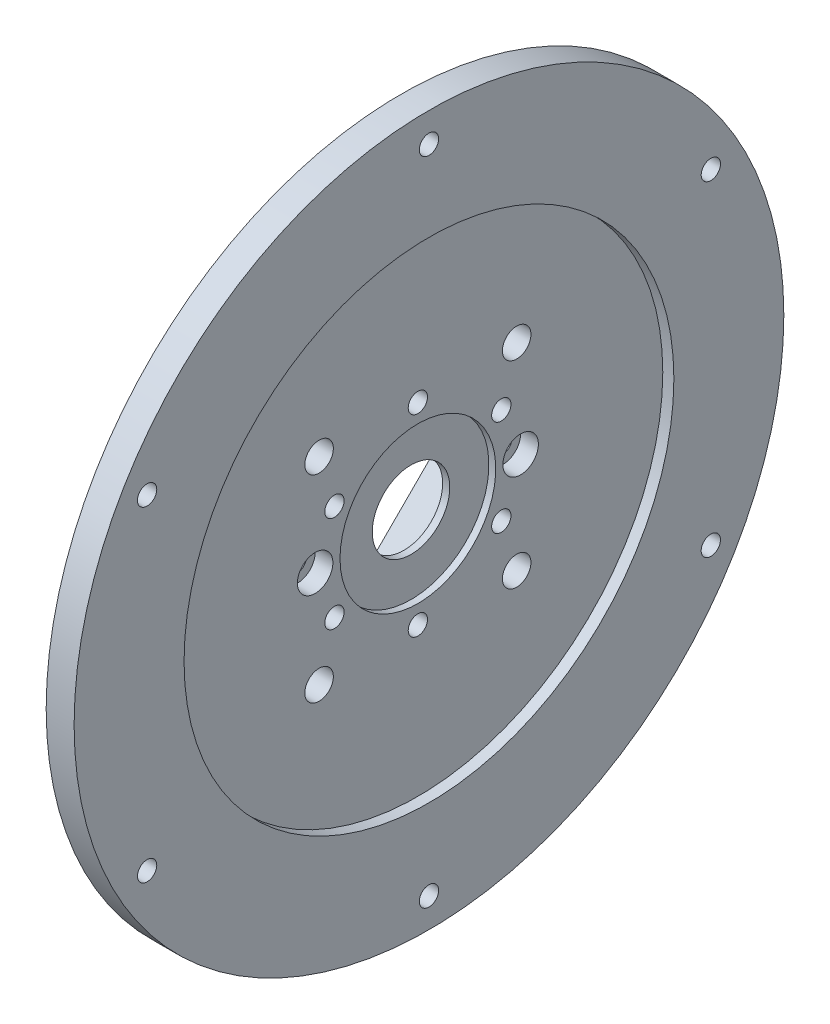
from build123d import *

# Parameters (mm, degrees)
SKETCH4_R               = 1.7272
CUT_EXTRUDE1_DEPTH      = 5.984800038
CUT_EXTRUDE1_DEPTH_BACK = 14.77519978
SKETCH5_R               = 1.5875
CUT_EXTRUDE2_DEPTH      = 17.775199622
SKETCH6_R               = 3.175
CUT_EXTRUDE3_DEPTH      = 3.175
BOSS_EXTRUDE1_REACH     = 20.76
FILLET1_R               = 3.175
SKETCH8_R               = 2.5527
CUT_EXTRUDE4_DEPTH      = 19.759999818


with BuildPart() as part:
    # Sketch2 → Revolve1 (revolve)
    with BuildSketch(Plane.XY):
        Polygon((-0.015199868, 29.999999944), (-1.815199824, 29.999999944), (-11.775199716, 29.999999944), (-13.77519978, 29.999999944), (-13.77519978, 25.4), (-2.000000064, 25.4), (-2.000000064, 11.499999987), (0.500000016, 11.499999987), (0.500000016, 6.937499968), (1.770899684, 6.937499968), (1.770899684, 7.9375), (1.770899684, 13.93649994), (2.999999842, 13.93649994), (2.999999842, 43.824999885), (4.984800038, 43.824999885), (4.984800038, 44.824999885), (4.984800038, 54.936499982), (4.984800038, 63.5), (-0.015199868, 63.5), align=None)
    revolve(axis=Axis((0, 0, 0), (1, 0, 0)))

    # Sketch4 → Cut-Extrude1 (cut, two sides)
    with BuildSketch(Plane(origin=(0, 0, 0), x_dir=(0, 0, -1), z_dir=(1, 0, 0))) as cut_extrude1_sk:
        with Locations((0, 58.238499982)):
            Circle(SKETCH4_R)
        with Locations((50.436020463, 29.119249991)):
            Circle(SKETCH4_R)
        with Locations((50.436020463, -29.119249991)):
            Circle(SKETCH4_R)
        with Locations((0, -58.238499982)):
            Circle(SKETCH4_R)
        with Locations((-50.436020463, -29.119249991)):
            Circle(SKETCH4_R)
        with Locations((-50.436020463, 29.119249991)):
            Circle(SKETCH4_R)
        with Locations((-14.928978871, 8.61924997)):
            Circle(SKETCH4_R)
        with Locations((0, 17.23849994)):
            Circle(SKETCH4_R)
        with Locations((14.928978871, 8.61924997)):
            Circle(SKETCH4_R)
        with Locations((14.928978871, -8.61924997)):
            Circle(SKETCH4_R)
        with Locations((0, -17.23849994)):
            Circle(SKETCH4_R)
        with Locations((-14.928978871, -8.61924997)):
            Circle(SKETCH4_R)
    extrude(amount=CUT_EXTRUDE1_DEPTH, mode=Mode.SUBTRACT)
    extrude(cut_extrude1_sk.sketch, amount=-CUT_EXTRUDE1_DEPTH_BACK, mode=Mode.SUBTRACT)

    # Sketch5 → Cut-Extrude2 (cut, through all)
    with BuildSketch(Plane(origin=(2.999999842, 0, 0), x_dir=(0, 0, -1), z_dir=(1, 0, 0))):
        with Locations((-18.385, 0)):
            Circle(SKETCH5_R)
        with Locations((18.385, 0)):
            Circle(SKETCH5_R)
    extrude(amount=-CUT_EXTRUDE2_DEPTH, mode=Mode.SUBTRACT)

    # Sketch6 → Cut-Extrude3 (cut)
    with BuildSketch(Plane(origin=(2.999999842, 0, 0), x_dir=(0, 0, -1), z_dir=(1, 0, 0))):
        with Locations((-18.385, 0)):
            Circle(SKETCH6_R)
        with Locations((18.385, 0)):
            Circle(SKETCH6_R)
    extrude(amount=-CUT_EXTRUDE3_DEPTH, mode=Mode.SUBTRACT)

    # Sketch7 → Boss-Extrude1 (add, up to next)
    with BuildSketch(Plane.ZY.offset(13.77519978), mode=Mode.PRIVATE) as boss_extrude1_sk1:
        with BuildLine():
            ThreePointArc((25.213720876, 3.070550371), (17.960512242, 17.960512242), (3.070550371, 25.213720876))
            Line((3.070550371, 25.213720876), (25.213720876, 3.070550371))
        make_face()
    boss_extrude1_tool1 = extrude(boss_extrude1_sk1.sketch, amount=-BOSS_EXTRUDE1_REACH, mode=Mode.PRIVATE) - part.part
    add(boss_extrude1_tool1.solids().sort_by_distance((-13.7752, 15.684318, 15.684318))[0])
    # Sketch7 → Boss-Extrude1 (add, up to next)
    with BuildSketch(Plane.ZY.offset(13.77519978), mode=Mode.PRIVATE) as boss_extrude1_sk2:
        with BuildLine():
            Line((-25.213720876, 3.070550371), (-3.070550371, 25.213720876))
            ThreePointArc((-3.070550371, 25.213720876), (-17.960512242, 17.960512242), (-25.213720876, 3.070550371))
        make_face()
    boss_extrude1_tool2 = extrude(boss_extrude1_sk2.sketch, amount=-BOSS_EXTRUDE1_REACH, mode=Mode.PRIVATE) - part.part
    add(boss_extrude1_tool2.solids().sort_by_distance((-13.7752, 15.684318, -15.684318))[0])
    # Sketch7 → Boss-Extrude1 (add, up to next)
    with BuildSketch(Plane.ZY.offset(13.77519978), mode=Mode.PRIVATE) as boss_extrude1_sk3:
        with BuildLine():
            Line((-3.070550371, -25.213720876), (-25.213720876, -3.070550371))
            ThreePointArc((-25.213720876, -3.070550371), (-17.960512242, -17.960512242), (-3.070550371, -25.213720876))
        make_face()
    boss_extrude1_tool3 = extrude(boss_extrude1_sk3.sketch, amount=-BOSS_EXTRUDE1_REACH, mode=Mode.PRIVATE) - part.part
    add(boss_extrude1_tool3.solids().sort_by_distance((-13.7752, -15.684318, -15.684318))[0])
    # Sketch7 → Boss-Extrude1 (add, up to next)
    with BuildSketch(Plane.ZY.offset(13.77519978), mode=Mode.PRIVATE) as boss_extrude1_sk4:
        with BuildLine():
            ThreePointArc((3.070550371, -25.213720876), (17.960512242, -17.960512242), (25.213720876, -3.070550371))
            Line((25.213720876, -3.070550371), (3.070550371, -25.213720876))
        make_face()
    boss_extrude1_tool4 = extrude(boss_extrude1_sk4.sketch, amount=-BOSS_EXTRUDE1_REACH, mode=Mode.PRIVATE) - part.part
    add(boss_extrude1_tool4.solids().sort_by_distance((-13.7752, -15.684318, 15.684318))[0])

    # Fillet1
    fillet1_edges = [part.edges().sort_by_distance(p)[0] for p in [
        (-7.887599922, 3.070550371, 25.213720876),
        (-7.887599922, 25.213720876, 3.070550371),
        (-7.887599922, 25.213720876, -3.070550371),
        (-7.887599922, 3.070550371, -25.213720876),
        (-7.887599922, -3.070550371, -25.213720876),
        (-7.887599922, -25.213720876, -3.070550371),
        (-7.887599922, -25.213720876, 3.070550371),
        (-7.887599922, -3.070550371, 25.213720876),
    ]]
    fillet(fillet1_edges, radius=FILLET1_R)

    # Sketch8 → Cut-Extrude4 (cut, through all)
    with BuildSketch(Plane.ZY.offset(13.77519978)):
        with Locations((17.67766951, 17.67766951)):
            Circle(SKETCH8_R)
        with Locations((17.67766951, -17.67766951)):
            Circle(SKETCH8_R)
        with Locations((-17.67766951, -17.67766951)):
            Circle(SKETCH8_R)
        with Locations((-17.67766951, 17.67766951)):
            Circle(SKETCH8_R)
    extrude(amount=-CUT_EXTRUDE4_DEPTH, mode=Mode.SUBTRACT)


solid = part.part
